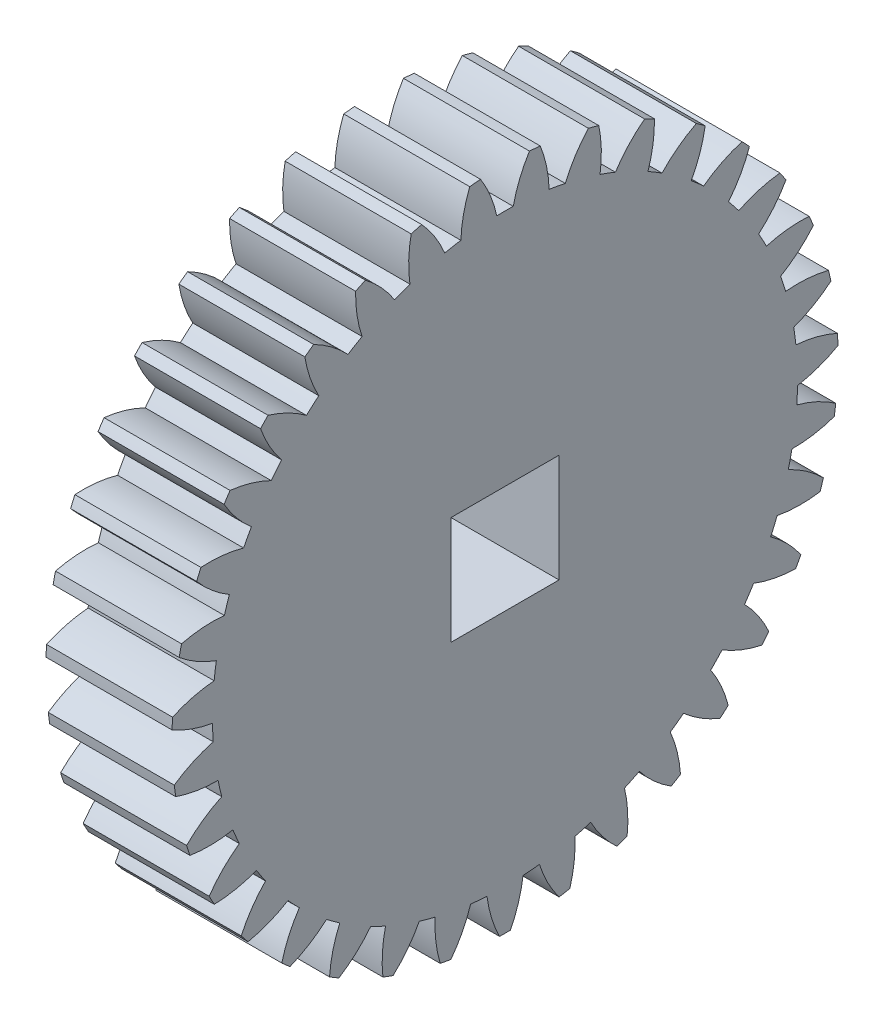
from build123d import *

# Parameters (mm, degrees)
BASPROSKE_W        = 7
BASPROSKE_H        = 18.5
TOOTHCUT_DEPTH     = 28.083205128
TEETHCUTS_COUNT    = 35
TEETHCUTS_ANGLE    = 349.714285714
BORSKE_R           = 1.5
BORE_DEPTH         = 50.0003556
SKETCH1_W          = 6
SKETCH1_H          = 6
CUT_EXTRUDE1_DEPTH = 10


with BuildPart() as part:
    # BasProSke → Base-Revolve (revolve)
    with BuildSketch(Plane(origin=(0, 0, 0), x_dir=(1, 0, 0), z_dir=(0, 1, 0)), mode=Mode.PRIVATE) as base_revolve_sk:
        with Locations((3.5, 9.25)):
            Rectangle(BASPROSKE_W, BASPROSKE_H)
    revolve(base_revolve_sk.sketch.rotate(Axis((-10, 0, 0), (1, 0, 0)), 180), axis=Axis((-10, 0, 0), (1, 0, 0)))

    # TooCutSke → ToothCut (cut, through all)
    with BuildSketch(Plane(origin=(0, 0, 0), x_dir=(0, 0, -1), z_dir=(1, 0, 0))):
        with BuildLine():
            ThreePointArc((0.456361119, 16.242590173), (0, 16.249), (-0.456361119, 16.242590173))
            ThreePointArc((-0.456361119, 16.242590173), (-0.817781123, 17.39831105), (-1.372969849, 18.474452602))
            ThreePointArc((-1.372969849, 18.474452602), (0, 18.5254), (1.372969849, 18.474452602))
            ThreePointArc((1.372969849, 18.474452602), (0.817781123, 17.39831105), (0.456361119, 16.242590173))
        make_face()
    toothcut = extrude(amount=TOOTHCUT_DEPTH, mode=Mode.SUBTRACT)

    # TeethCuts: ToothCut ×35 about axis
    teethcuts_axis = Axis((-10, 0, 0), (1, 0, 0))
    for i in range(1, TEETHCUTS_COUNT):
        add(toothcut.rotate(teethcuts_axis, i * TEETHCUTS_ANGLE / (TEETHCUTS_COUNT - 1)), mode=Mode.SUBTRACT)

    # BorSke → Bore (cut, symmetric)
    with BuildSketch(Plane(origin=(0, 0, 0), x_dir=(0, 0, -1), z_dir=(1, 0, 0))):
        with Locations(Location((0, 0, 0), (0, 0, 180))):
            Circle(BORSKE_R)
    extrude(amount=BORE_DEPTH, both=True, mode=Mode.SUBTRACT)

    # Sketch1 → Cut-Extrude1 (cut)
    with BuildSketch(Plane(origin=(7, 0, 0), x_dir=(0, 0, -1), z_dir=(1, 0, 0))):
        Rectangle(SKETCH1_W, SKETCH1_H)
    extrude(amount=-CUT_EXTRUDE1_DEPTH, mode=Mode.SUBTRACT)


solid = part.part
